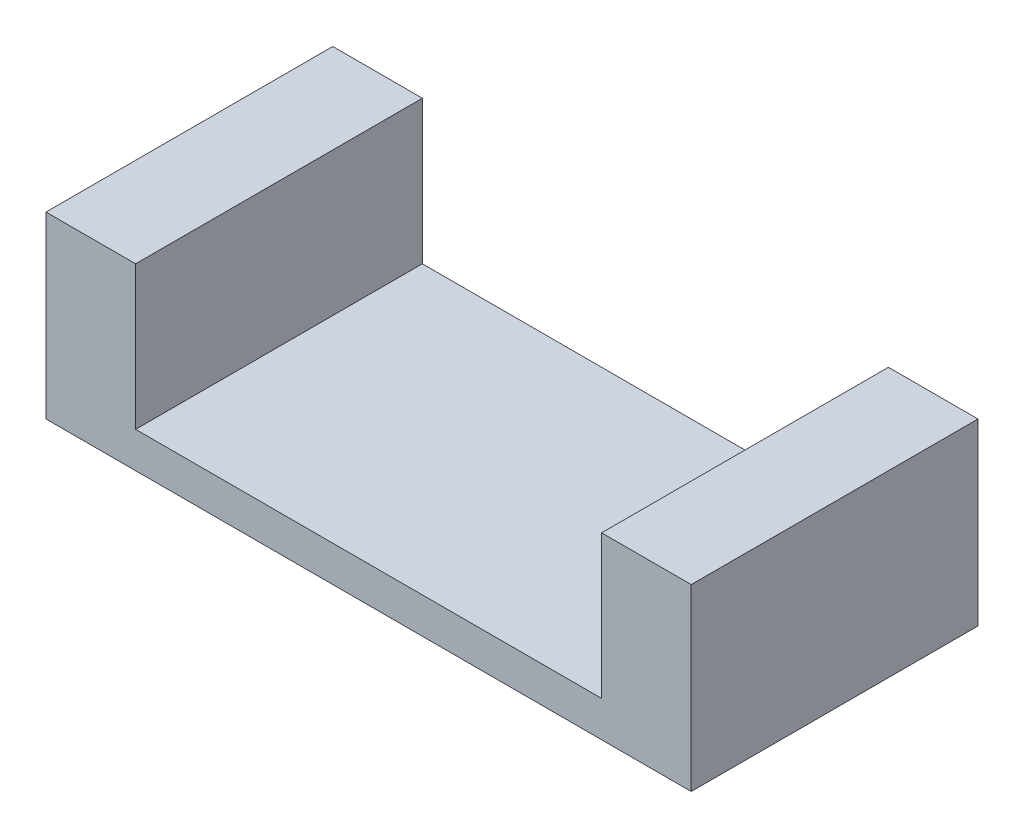
from build123d import *

# Parameters (mm, degrees)
BOSS_EXTRUDE3_DEPTH = 0.8


with BuildPart() as part:
    # Sketch4 → Boss-Extrude3 (new body)
    with BuildSketch(Plane.XY):
        Polygon((-1.8, 0.5), (-1.55, 0.5), (-1.55, 0.1), (-0.25, 0.1), (-0.25, 0.5), (0, 0.5), (0, 0), (-1.8, 0), align=None)
    extrude(amount=BOSS_EXTRUDE3_DEPTH)


solid = part.part
